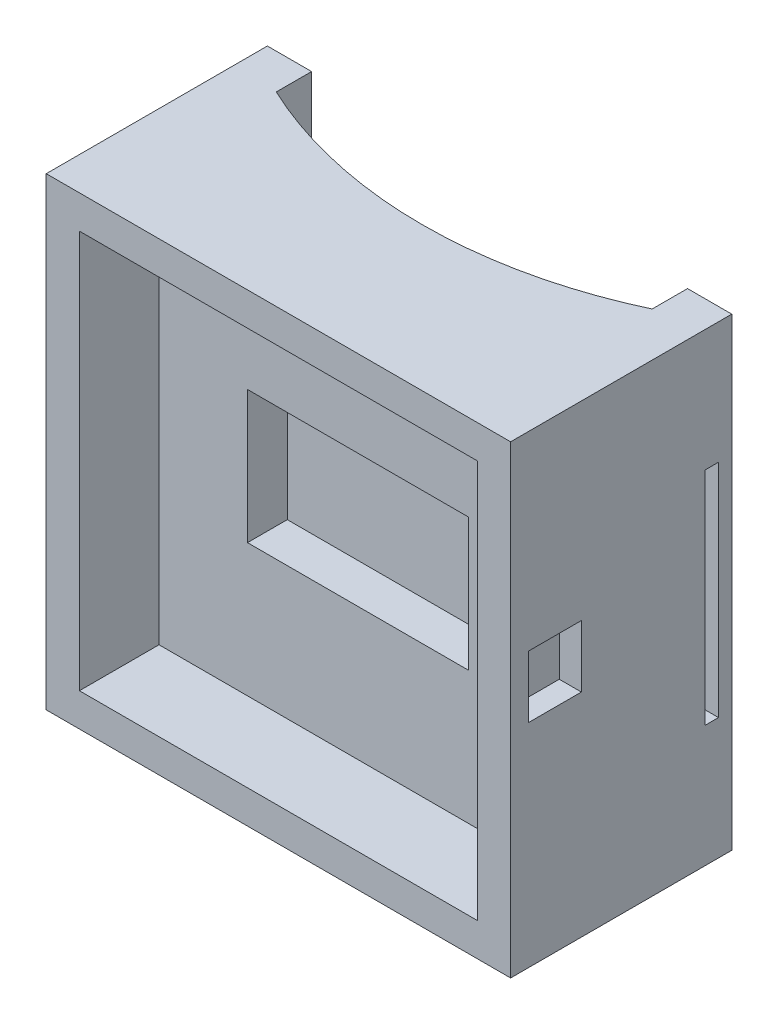
from build123d import *

# Parameters (mm, degrees)
SKETCH1_W           = 105
SKETCH1_H           = 105
BOSS_EXTRUDE1_DEPTH = 50
CUT_EXTRUDE1_DEPTH  = 106
SKETCH3_W           = 90
SKETCH3_H           = 90
CUT_EXTRUDE2_DEPTH  = 18
SKETCH4_W           = 50
SKETCH4_H           = 30
CUT_EXTRUDE3_DEPTH  = 9
SKETCH5_W           = 3
SKETCH5_H           = 50
CUT_EXTRUDE4_DEPTH  = 106
SKETCH7_W           = 12
SKETCH7_H           = 14
CUT_EXTRUDE5_DEPTH  = 5


with BuildPart() as part:
    # Sketch1 → Boss-Extrude1 (new body)
    with BuildSketch(Plane.XY):
        Rectangle(SKETCH1_W, SKETCH1_H)
    extrude(amount=BOSS_EXTRUDE1_DEPTH)

    # Sketch2 → Cut-Extrude1 (cut, through all)
    with BuildSketch(Plane.XZ.offset(52.5)):
        with BuildLine():
            Line((-42.5, 8), (-42.5, 0))
            Line((-42.5, 0), (42.5, 0))
            Line((42.5, 0), (42.5, 8))
            ThreePointArc((42.5, 8), (0, 17.480665049), (-42.5, 8))
        make_face()
    extrude(amount=-CUT_EXTRUDE1_DEPTH, mode=Mode.SUBTRACT)

    # Sketch3 → Cut-Extrude2 (cut)
    with BuildSketch(Plane.XY.offset(50)):
        Rectangle(SKETCH3_W, SKETCH3_H)
    extrude(amount=-CUT_EXTRUDE2_DEPTH, mode=Mode.SUBTRACT)

    # Sketch4 → Cut-Extrude3 (cut)
    with BuildSketch(Plane.XY.offset(32)):
        Rectangle(SKETCH4_W, SKETCH4_H)
    extrude(amount=-CUT_EXTRUDE3_DEPTH, mode=Mode.SUBTRACT)

    # Sketch5 → Cut-Extrude4 (cut, through all)
    with BuildSketch(Plane.ZY.offset(52.5)):
        with Locations((4.5, 0)):
            Rectangle(SKETCH5_W, SKETCH5_H)
    extrude(amount=-CUT_EXTRUDE4_DEPTH, mode=Mode.SUBTRACT)

    # Sketch7 → Cut-Extrude5 (cut)
    with BuildSketch(Plane(origin=(52.5, 0, 0), x_dir=(0, 0, -1), z_dir=(1, 0, 0))):
        with Locations((-40, 2.495495841)):
            Rectangle(SKETCH7_W, SKETCH7_H)
    extrude(amount=-CUT_EXTRUDE5_DEPTH, mode=Mode.SUBTRACT)


solid = part.part
